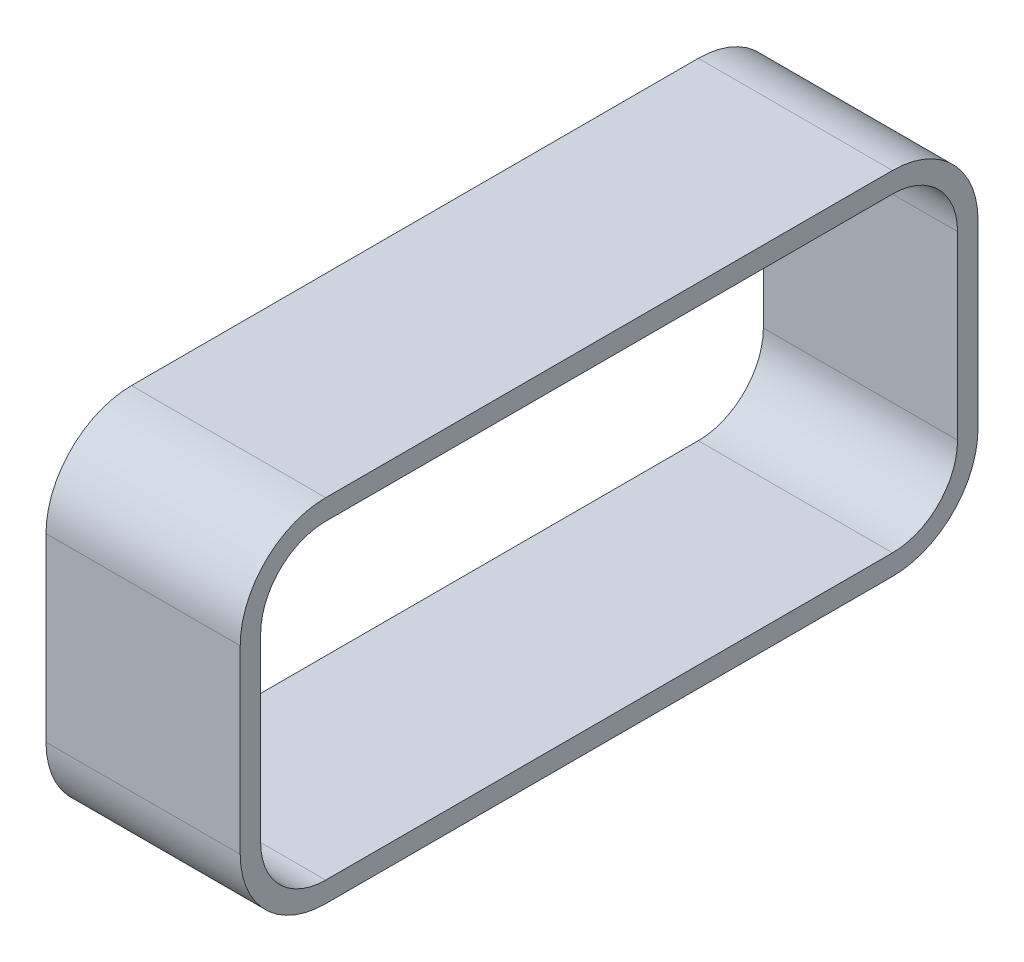
from build123d import *

# Parameters (mm, degrees)
BOSS_EXTRUDE1_DEPTH = 1045


with BuildPart() as part:
    # Sketch1 → Boss-Extrude1 (new body)
    with BuildSketch(Plane(origin=(0, 0, 0), x_dir=(0, 0, -1), z_dir=(1, 0, 0))):
        with BuildLine():
            Line((-460, 1322), (-460, 350))
            ThreePointArc((-460, 350), (-325.269119346, 24.730880654), (0, -110))
            Line((0, -110), (3050, -110))
            ThreePointArc((3050, -110), (3375.269119346, 24.730880654), (3510, 350))
            Line((3510, 350), (3510, 1322))
            ThreePointArc((3510, 1322), (3375.269119346, 1647.269119346), (3050, 1782))
            Line((3050, 1782), (0, 1782))
            ThreePointArc((0, 1782), (-325.269119346, 1647.269119346), (-460, 1322))
        make_face()
        with BuildLine():
            Line((0, 0), (3050, 0))
            ThreePointArc((3050, 0), (3297.487373415, 102.512626585), (3400, 350))
            Line((3400, 350), (3400, 1322))
            ThreePointArc((3400, 1322), (3297.487373415, 1569.487373415), (3050, 1672))
            Line((3050, 1672), (0, 1672))
            ThreePointArc((0, 1672), (-247.487373415, 1569.487373415), (-350, 1322))
            Line((-350, 1322), (-350, 350))
            ThreePointArc((-350, 350), (-247.487373415, 102.512626585), (0, 0))
        make_face(mode=Mode.SUBTRACT)
    extrude(amount=BOSS_EXTRUDE1_DEPTH)


solid = part.part
